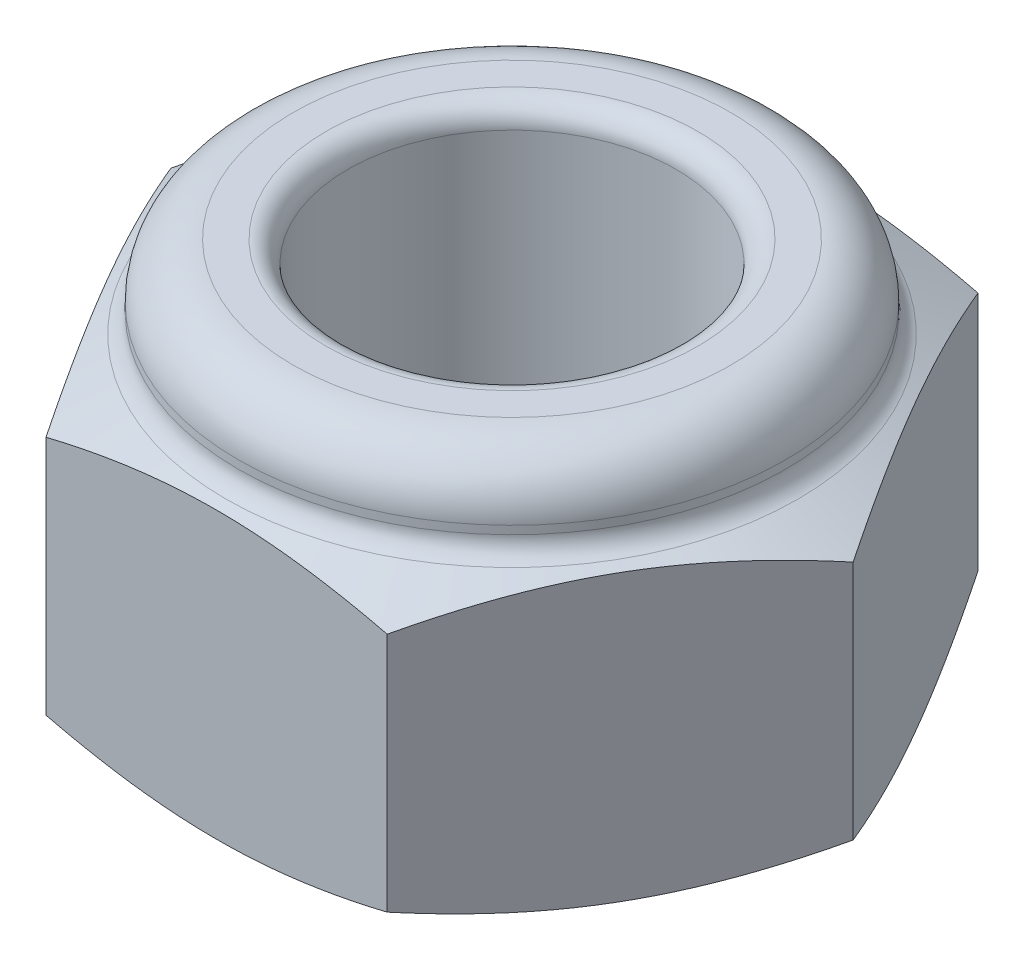
from build123d import *

# Parameters (mm, degrees)
EXTRUDE_1_DEPTH     = 1.4
SKETCH_3_R          = 1.5
CUT_EXTRUDE_1_DEPTH = 3.8
FILLET_1_R          = 0.2


with BuildPart() as part:
    # 草图1 → 凸台-拉伸1 (new body, symmetric)
    with BuildSketch(Plane(origin=(0, 0, 0), x_dir=(1, 0, 0), z_dir=(0, 1, 0))):
        Polygon((3.117691454, 0), (1.558845727, 2.7), (-1.558845727, 2.7), (-3.117691454, 0), (-1.558845727, -2.7), (1.558845727, -2.7), align=None)
    extrude(amount=EXTRUDE_1_DEPTH, both=True)

    # 草图2 → 切除-旋转1 (revolve, cut)
    with BuildSketch(Plane.XY):
        Polygon((-3.117691454, 1.1), (-2.5, 1.4), (-3.117691454, 1.4), align=None)
    cut_revolve_1 = revolve(axis=Axis((0, 0, 0), (0, 1, 0)), mode=Mode.SUBTRACT)

    # 镜向3: 切除-旋转1 across plane
    add(cut_revolve_1.mirror(Plane.ZX), mode=Mode.SUBTRACT)

    # 草图3 → 切除-拉伸1 (cut, through all)
    with BuildSketch(Plane(origin=(0, 1.4, 0), x_dir=(1, 0, 0), z_dir=(0, 1, 0))):
        Circle(SKETCH_3_R)
    extrude(amount=-CUT_EXTRUDE_1_DEPTH, mode=Mode.SUBTRACT)

    # 草图4 → 旋转1 (revolve)
    with BuildSketch(Plane(origin=(0, 0, 0), x_dir=(0, 0, -1), z_dir=(1, 0, 0))):
        with BuildLine():
            Line((-2.5, 1.4), (-2.5, 1.6))
            ThreePointArc((-2.5, 1.6), (-2.353553391, 1.953553391), (-2, 2.1))
            Line((-2, 2.1), (-1.5, 2.1))
            Line((-1.5, 2.1), (-1.5, 1.4))
            Line((-1.5, 1.4), (-2.5, 1.4))
        make_face()
    revolve(axis=Axis((0, 1.4, 0), (0, -1, 0)))

    # 圆角1
    fillet_1_edges = [part.edges().sort_by_distance(p)[0] for p in [
        (-1.767766953, 1.4, 1.767766953),
        (0, 2.1, -1.5),
    ]]
    fillet(fillet_1_edges, radius=FILLET_1_R)


solid = part.part
